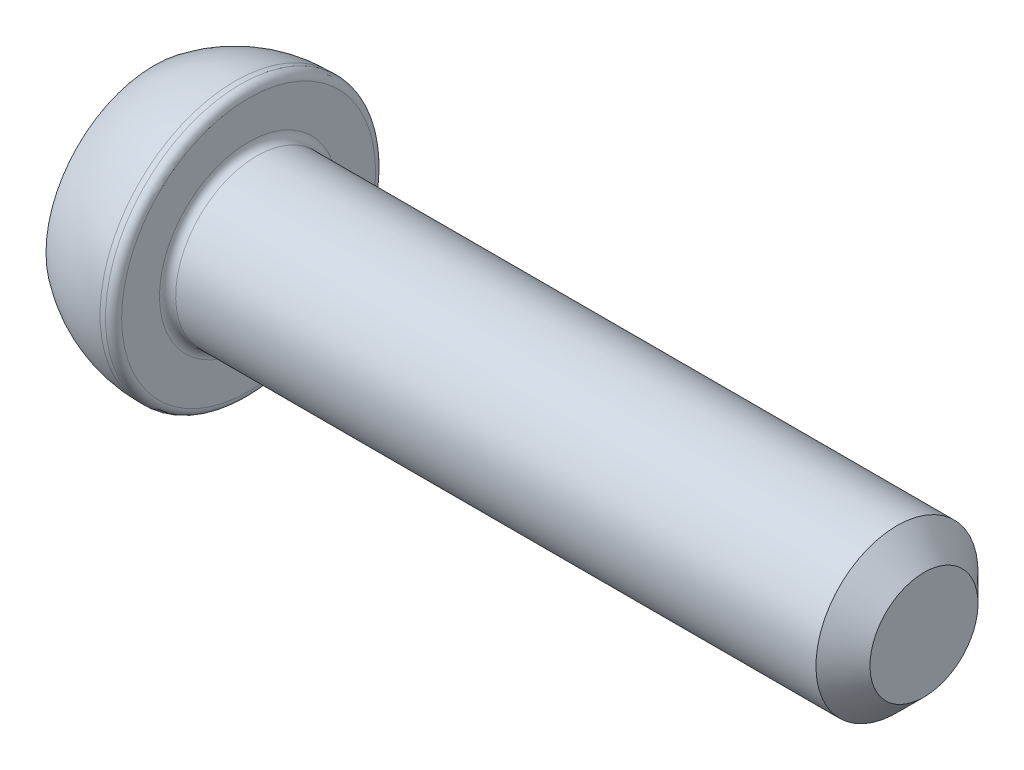
from build123d import *

# Parameters (mm, degrees)
CUT_EXTRUDE_1_DEPTH = 2
FILLET_1_R          = 0.3
CHAMFER_1_SIZE      = 1


with BuildPart() as part:
    # Эскиз1 → Повернуть1 (revolve)
    with BuildSketch(Plane.XY):
        with BuildLine():
            Line((0, 0), (0, 4))
            ThreePointArc((0, 4), (1.41886117, 4.74341649), (3, 5))
            Line((3, 5), (3.5, 5))
            Line((3.5, 5), (3.5, 3))
            Line((3.5, 3), (28.5, 3))
            Line((28.5, 3), (28.5, 0))
            Line((28.5, 0), (0, 0))
        make_face()
    revolve(axis=Axis((28.5, 0, 0), (-1, 0, 0)))

    # Эскиз2 → Вырез-Вытянуть1 (cut)
    with BuildSketch(Plane.ZY):
        Polygon((1.154700538, 2), (-1.154700538, 2), (-2.309401077, 0), (-1.154700538, -2), (1.154700538, -2), (2.309401077, 0), align=None)
    extrude(amount=-CUT_EXTRUDE_1_DEPTH, mode=Mode.SUBTRACT)

    # Скругление1
    fillet_1_edges = [part.edges().sort_by_distance(p)[0] for p in [
        (3.5, -3, 0),
        (3.5, -5, 0),
    ]]
    fillet(fillet_1_edges, radius=FILLET_1_R)

    # Фаска1
    chamfer_1_edges = [part.edges().sort_by_distance(p)[0] for p in [
        (28.5, -3, 0),
    ]]
    chamfer(chamfer_1_edges, length=CHAMFER_1_SIZE)


solid = part.part
